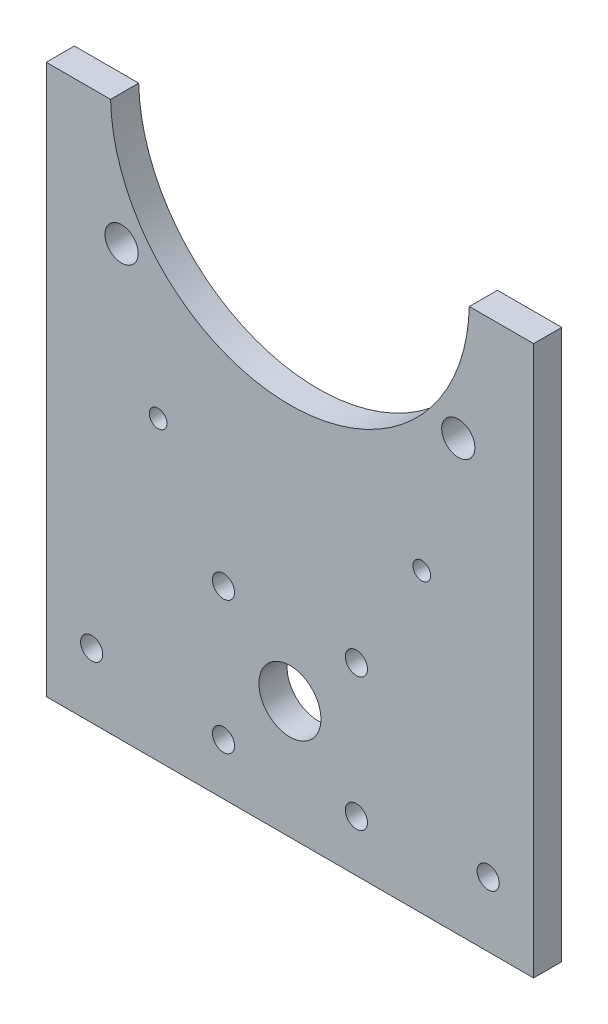
from build123d import *

# Parameters (mm, degrees)
CROQUIS1_R              = 3.75
CROQUIS1_R_2            = 2
CROQUIS1_R_3            = 2.5
SALIENTE_EXTRUIR1_DEPTH = 6.35
CROQUIS2_R              = 7
CROQUIS2_R_2            = 2.5
CORTAR_EXTRUIR1_DEPTH   = 10


with BuildPart() as part:
    # Croquis1 → Saliente-Extruir1 (new body)
    with BuildSketch(Plane.XY):
        with BuildLine():
            Line((0, 0), (-110, 0))
            Line((-110, 0), (-110, 124))
            Line((-110, 124), (-95.487652439, 124))
            ThreePointArc((-95.487652439, 124), (-55, 84.5), (-14.512347561, 124))
            Line((-14.512347561, 124), (0, 124))
            Line((0, 124), (0, 0))
        make_face()
        with Locations((-93, 97)):
            Circle(CROQUIS1_R, mode=Mode.SUBTRACT)
        with Locations((-84.75, 67)):
            Circle(CROQUIS1_R_2, mode=Mode.SUBTRACT)
        with Locations((-25.25, 67)):
            Circle(CROQUIS1_R_2, mode=Mode.SUBTRACT)
        with Locations((-17, 97)):
            Circle(CROQUIS1_R, mode=Mode.SUBTRACT)
        with Locations((-99.75, 14.601014199)):
            Circle(CROQUIS1_R_3, mode=Mode.SUBTRACT)
        with Locations((-10.25, 14.601014199)):
            Circle(CROQUIS1_R_3, mode=Mode.SUBTRACT)
    extrude(amount=SALIENTE_EXTRUIR1_DEPTH)

    # Croquis2 → Cortar-Extruir1 (cut)
    with BuildSketch(Plane.XY.offset(6.35)):
        with Locations((-55, 26.601014199)):
            Circle(CROQUIS2_R)
        with Locations((-40, 11.601014199)):
            Circle(CROQUIS2_R_2)
        with Locations((-70, 11.601014199)):
            Circle(CROQUIS2_R_2)
        with Locations((-70, 41.601014199)):
            Circle(CROQUIS2_R_2)
        with Locations((-40, 41.601014199)):
            Circle(CROQUIS2_R_2)
    extrude(amount=-CORTAR_EXTRUIR1_DEPTH, mode=Mode.SUBTRACT)


solid = part.part
